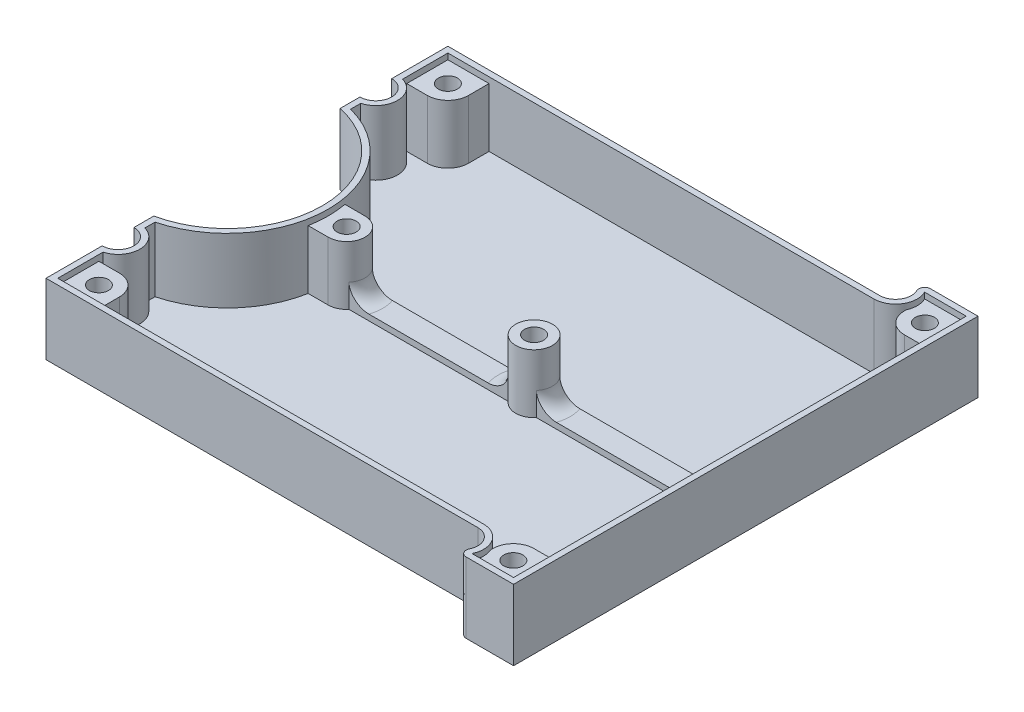
from build123d import *

# Parameters (mm, degrees)
BASE_SHAPE_DEPTH           = 12
FILLETS_R                  = 1
INSIDE_CUT_DEPTH           = 11
SKETCH3_R                  = 1.625
SKETCH3_R_2                = 3.125
MOUNTING_POSTS_DEPTH       = 10
CENTER_REINFORCEMENT_DEPTH = 1
REINFORCEMENT_FILLETS_R    = 3


with BuildPart() as part:
    # Sketch1 → Base shape (new body)
    with BuildSketch(Plane(origin=(0, 0, 0), x_dir=(1, 0, 0), z_dir=(0, 1, 0))):
        with BuildLine():
            ThreePointArc((2.7, 36.88), (1.909188309, 34.970811691), (0, 34.18))
            Line((0, 34.18), (-73.452025159, 34.18))
            Line((-73.452025159, 34.18), (-73.452025159, 24.62))
            ThreePointArc((-73.452025159, 24.62), (-71.54283685, 23.829188309), (-70.752025159, 21.92))
            ThreePointArc((-70.752025159, 21.92), (-71.54283685, 20.010811691), (-73.452025159, 19.22))
            Line((-73.452025159, 19.22), (-73.452025159, 15.845601913))
            ThreePointArc((-73.452025159, 15.845601913), (-64.231671709, 10.194263093), (-60.622025159, 0))
            ThreePointArc((-60.622025159, 0), (-64.231671709, -10.194263093), (-73.452025159, -15.845601913))
            Line((-73.452025159, -15.845601913), (-73.452025159, -19.22))
            ThreePointArc((-73.452025159, -19.22), (-71.54283685, -20.010811691), (-70.752025159, -21.92))
            ThreePointArc((-70.752025159, -21.92), (-71.54283685, -23.829188309), (-73.452025159, -24.62))
            Line((-73.452025159, -24.62), (-73.452025159, -34.18))
            Line((-73.452025159, -34.18), (0, -34.18))
            ThreePointArc((0, -34.18), (1.909188309, -34.970811691), (2.7, -36.88))
            ThreePointArc((2.7, -36.88), (2.127372404, -38.542614403), (0.652380257, -39.5))
            Line((0.652380257, -39.5), (11.4, -39.5))
            Line((11.4, -39.5), (11.4, 39.5))
            Line((11.4, 39.5), (0.652380257, 39.5))
            ThreePointArc((0.652380257, 39.5), (2.127372404, 38.542614403), (2.7, 36.88))
        make_face()
    extrude(amount=BASE_SHAPE_DEPTH)

    # Fillets
    fillets_edges = [part.edges().sort_by_distance(p)[0] for p in [
        (0.652380257, 6, -39.5),
        (0.652380257, 6, 39.5),
    ]]
    fillet(fillets_edges, radius=FILLETS_R)

    # Sketch2 → Inside cut (cut)
    with BuildSketch(Plane(origin=(0, 12, 0), x_dir=(1, 0, 0), z_dir=(0, 1, 0))):
        with BuildLine():
            Line((10.4, 38.5), (3.326499662, 38.5))
            ThreePointArc((3.326499662, 38.5), (3.1371962, 34.918368026), (0, 33.18))
            Line((0, 33.18), (-72.452025159, 33.18))
            Line((-72.452025159, 33.18), (-72.452025159, 25.482302626))
            ThreePointArc((-72.452025159, 25.482302626), (-69.752025159, 21.92), (-72.452025159, 18.357697374))
            Line((-72.452025159, 18.357697374), (-72.452025159, 16.635597374))
            ThreePointArc((-72.452025159, 16.635597374), (-59.622025159, 0), (-72.452025159, -16.635597374))
            Line((-72.452025159, -16.635597374), (-72.452025159, -18.357697374))
            ThreePointArc((-72.452025159, -18.357697374), (-69.752025159, -21.92), (-72.452025159, -25.482302626))
            Line((-72.452025159, -25.482302626), (-72.452025159, -33.18))
            Line((-72.452025159, -33.18), (0, -33.18))
            ThreePointArc((0, -33.18), (3.1371962, -34.918368026), (3.326499662, -38.5))
            Line((3.326499662, -38.5), (10.4, -38.5))
            Line((10.4, -38.5), (10.4, 38.5))
        make_face()
    extrude(amount=-INSIDE_CUT_DEPTH, mode=Mode.SUBTRACT)

    # Sketch3 → Mounting posts (add)
    with BuildSketch(Plane(origin=(0, 1, 0), x_dir=(1, 0, 0), z_dir=(0, 1, 0))):
        with BuildLine():
            Line((-72.452025159, 26.18), (-68.952025159, 26.18))
            ThreePointArc((-68.952025159, 26.18), (-66.477151425, 27.205126266), (-65.452025159, 29.68))
            Line((-65.452025159, 29.68), (-65.452025159, 33.18))
            Line((-65.452025159, 33.18), (-72.452025159, 33.18))
            Line((-72.452025159, 33.18), (-72.452025159, 26.18))
        make_face()
        with Locations((-68.952025159, 29.68)):
            Circle(SKETCH3_R, mode=Mode.SUBTRACT)
        with BuildLine():
            ThreePointArc((3.384479038, 35.38490748), (4.255839604, 32.665174116), (6.863249831, 31.5))
            Line((6.863249831, 31.5), (10.4, 31.5))
            Line((10.4, 31.5), (10.4, 38.5))
            Line((10.4, 38.5), (3.326499662, 38.5))
            ThreePointArc((3.326499662, 38.5), (3.699359286, 36.948853988), (3.384479038, 35.38490748))
        make_face()
        with Locations((6.863249831, 35)):
            Circle(SKETCH3_R, mode=Mode.SUBTRACT)
        with BuildLine():
            Line((-56.497025159, 3.125), (-59.908291834, 3.125))
            ThreePointArc((-59.908291834, 3.125), (-59.622025159, 0), (-59.908291834, -3.125))
            Line((-59.908291834, -3.125), (-56.497025159, -3.125))
            ThreePointArc((-56.497025159, -3.125), (-53.372025159, 0), (-56.497025159, 3.125))
        make_face()
        with Locations((-56.497025159, 0)):
            Circle(SKETCH3_R, mode=Mode.SUBTRACT)
        with BuildLine():
            Line((10.4, -38.5), (10.4, -31.5))
            Line((10.4, -31.5), (6.863249831, -31.5))
            ThreePointArc((6.863249831, -31.5), (4.255839604, -32.665174116), (3.384479038, -35.38490748))
            ThreePointArc((3.384479038, -35.38490748), (3.699359286, -36.948853988), (3.326499662, -38.5))
            Line((3.326499662, -38.5), (10.4, -38.5))
        make_face()
        with Locations((6.863249831, -35)):
            Circle(SKETCH3_R, mode=Mode.SUBTRACT)
        with BuildLine():
            Line((-68.952025159, -26.18), (-72.452025159, -26.18))
            Line((-72.452025159, -26.18), (-72.452025159, -33.18))
            Line((-72.452025159, -33.18), (-65.452025159, -33.18))
            Line((-65.452025159, -33.18), (-65.452025159, -29.68))
            ThreePointArc((-65.452025159, -29.68), (-66.477151425, -27.205126266), (-68.952025159, -26.18))
        make_face()
        with Locations((-68.952025159, -29.68)):
            Circle(SKETCH3_R, mode=Mode.SUBTRACT)
        with Locations((-24.61101258, 0)):
            Circle(SKETCH3_R_2)
        with Locations((-24.61101258, 0)):
            Circle(SKETCH3_R, mode=Mode.SUBTRACT)
    extrude(amount=MOUNTING_POSTS_DEPTH)

    # Sketch4 → Center reinforcement (add)
    with BuildSketch(Plane(origin=(0, 1, 0), x_dir=(1, 0, 0), z_dir=(0, 1, 0))):
        with BuildLine():
            Line((-27.012184169, 2), (-54.09585357, 2))
            ThreePointArc((-54.09585357, 2), (-53.372025159, 0), (-54.09585357, -2))
            Line((-54.09585357, -2), (-27.012184169, -2))
            ThreePointArc((-27.012184169, -2), (-27.73601258, 0), (-27.012184169, 2))
        make_face()
        with BuildLine():
            Line((10.4, 2), (-22.209840991, 2))
            ThreePointArc((-22.209840991, 2), (-21.672536255, 1.063476324), (-21.48601258, 0))
            ThreePointArc((-21.48601258, 0), (-21.672536255, -1.063476324), (-22.209840991, -2))
            Line((-22.209840991, -2), (10.4, -2))
            Line((10.4, -2), (10.4, 2))
        make_face()
    extrude(amount=CENTER_REINFORCEMENT_DEPTH)

    # Reinforcement fillets
    reinforcement_fillets_edges = [part.edges().sort_by_distance(p)[0] for p in [
        (-53.372025159, 2, 0),
        (-27.73601258, 2, 0),
        (-21.672536255, 2, 1.063476324),
        (10.4, 2, 0),
    ]]
    fillet(reinforcement_fillets_edges, radius=REINFORCEMENT_FILLETS_R)


solid = part.part
